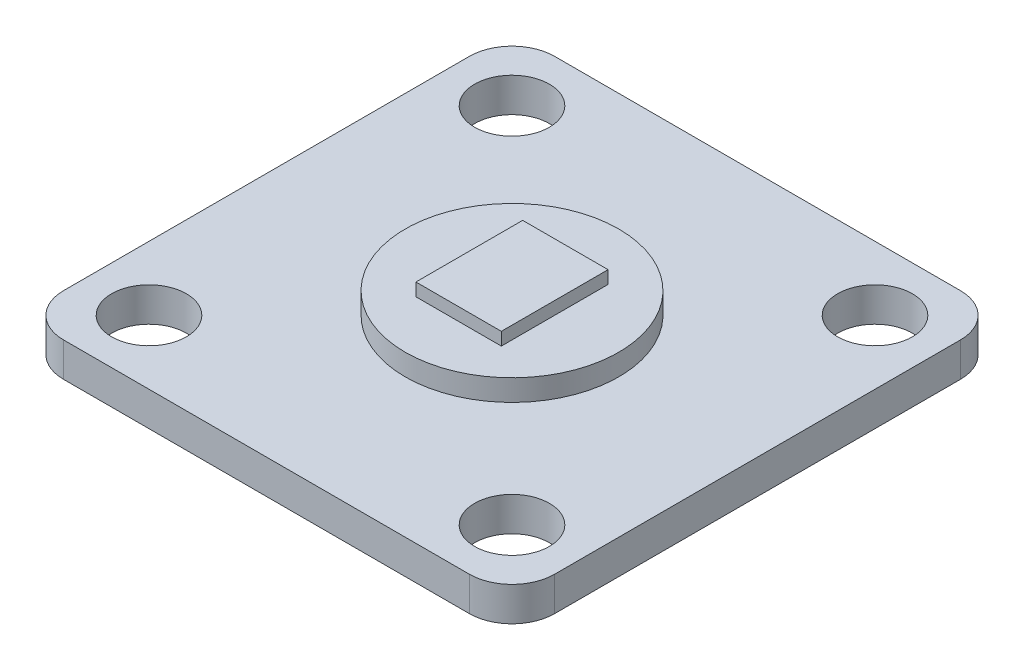
from build123d import *

# Parameters (mm, degrees)
SKETCH1_R           = 1.75
BOSS_EXTRUDE1_DEPTH = 1.6
SKETCH2_W           = 4
SKETCH2_H           = 5
BOSS_EXTRUDE2_DEPTH = 1.6
SKETCH3_R           = 5
BOSS_EXTRUDE3_DEPTH = 1


with BuildPart() as part:
    # Sketch1 → Boss-Extrude1 (new body)
    with BuildSketch(Plane(origin=(0, 0, 0), x_dir=(1, 0, 0), z_dir=(0, 1, 0))):
        with BuildLine():
            Line((-9.5, -11.5), (9.5, -11.5))
            ThreePointArc((9.5, -11.5), (10.914213562, -10.914213562), (11.5, -9.5))
            Line((11.5, -9.5), (11.5, 9.5))
            ThreePointArc((11.5, 9.5), (10.914213562, 10.914213562), (9.5, 11.5))
            Line((9.5, 11.5), (-9.5, 11.5))
            ThreePointArc((-9.5, 11.5), (-10.914213562, 10.914213562), (-11.5, 9.5))
            Line((-11.5, 9.5), (-11.5, -9.5))
            ThreePointArc((-11.5, -9.5), (-10.914213562, -10.914213562), (-9.5, -11.5))
        make_face()
        with Locations((8.5, 8.5)):
            Circle(SKETCH1_R, mode=Mode.SUBTRACT)
        with Locations((8.5, -8.5)):
            Circle(SKETCH1_R, mode=Mode.SUBTRACT)
        with Locations((-8.5, -8.5)):
            Circle(SKETCH1_R, mode=Mode.SUBTRACT)
        with Locations((-8.5, 8.5)):
            Circle(SKETCH1_R, mode=Mode.SUBTRACT)
    extrude(amount=BOSS_EXTRUDE1_DEPTH)

    # Sketch2 → Boss-Extrude2 (add)
    with BuildSketch(Plane(origin=(0, 1.6, 0), x_dir=(1, 0, 0), z_dir=(0, 1, 0))):
        Rectangle(SKETCH2_W, SKETCH2_H)
    extrude(amount=BOSS_EXTRUDE2_DEPTH)

    # Sketch3 → Boss-Extrude3 (add)
    with BuildSketch(Plane(origin=(0, 1.6, 0), x_dir=(1, 0, 0), z_dir=(0, 1, 0))):
        Circle(SKETCH3_R)
    extrude(amount=BOSS_EXTRUDE3_DEPTH)


solid = part.part
